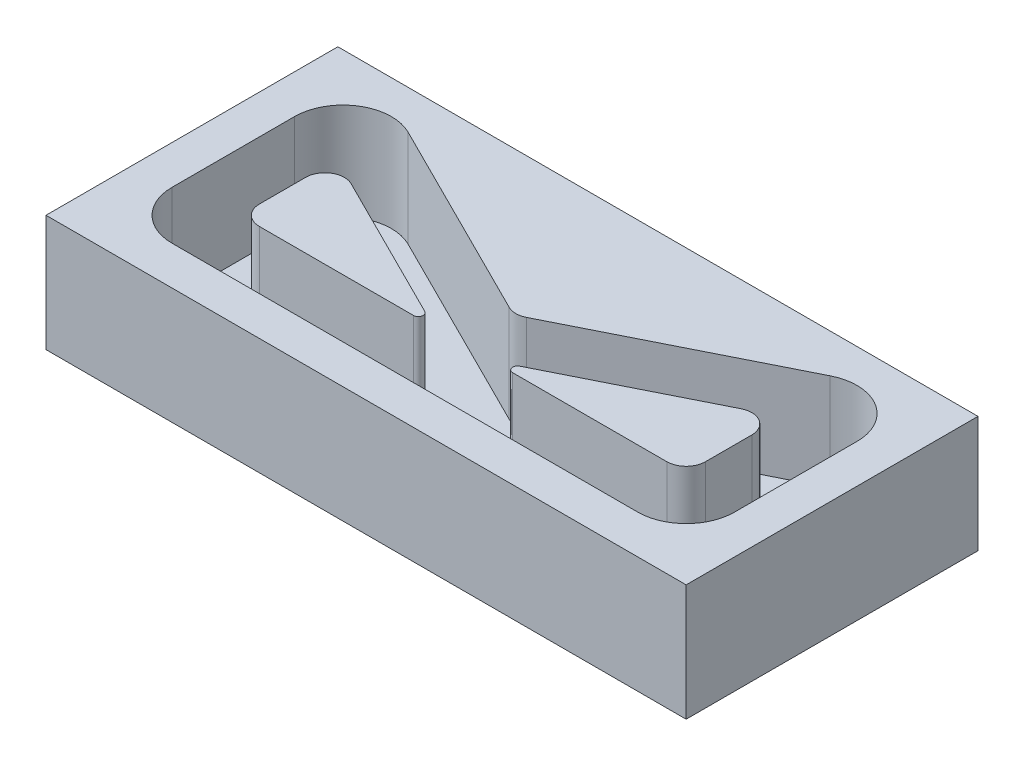
from build123d import *

# Parameters (mm, degrees)
BOSS_EXTRUDE1_DEPTH   = 5
BOSS_EXTRUDE1_2_DEPTH = 5
SKETCH1_W             = 33
SKETCH1_H             = 15.045084972
BOSS_EXTRUDE1_3_DEPTH = 5
SKETCH2_W             = 33
SKETCH2_H             = 15.045084972
BOSS_EXTRUDE3_DEPTH   = 1


with BuildPart() as part:
    # Sketch1 → Boss-Extrude1 (new body)
    with BuildSketch(Plane(origin=(0, 0, 0), x_dir=(1, 0, 0), z_dir=(0, 1, 0))):
        with BuildLine():
            Line((-0.947213595, 0.473606798), (-8.552786405, 4.276393202))
            ThreePointArc((-8.552786405, 4.276393202), (-9.525731112, 4.23261682), (-10, 3.381966011))
            Line((-10, 3.381966011), (-10, 1))
            ThreePointArc((-10, 1), (-9.707106781, 0.292893219), (-9, 0))
            Line((-9, 0), (-1.059016994, 0))
            ThreePointArc((-1.059016994, 0), (-0.815704747, 0.19256177), (-0.947213595, 0.473606798))
        make_face()
    extrude(amount=BOSS_EXTRUDE1_DEPTH)



with BuildPart() as body_2:
    # Sketch1 → Boss-Extrude1 2 (new body)
    with BuildSketch(Plane(origin=(0, 0, 0), x_dir=(1, 0, 0), z_dir=(0, 1, 0))):
        with BuildLine():
            Line((12, 0), (4.059016994, 0))
            ThreePointArc((4.059016994, 0), (3.815704747, 0.19256177), (3.947213595, 0.473606798))
            Line((3.947213595, 0.473606798), (11.552786405, 4.276393202))
            ThreePointArc((11.552786405, 4.276393202), (12.525731112, 4.23261682), (13, 3.381966011))
            Line((13, 3.381966011), (13, 1))
            ThreePointArc((13, 1), (12.707106781, 0.292893219), (12, 0))
        make_face()
    extrude(amount=BOSS_EXTRUDE1_2_DEPTH)


with BuildPart() as body_3:
    # Sketch1 → Boss-Extrude1 3 (new body)
    with BuildSketch(Plane(origin=(0, 0, 0), x_dir=(1, 0, 0), z_dir=(0, 1, 0))):
        with Locations((1.5, 2.522542486)):
            Rectangle(SKETCH1_W, SKETCH1_H)
        with BuildLine():
            Line((1.052786405, 2.827708764), (-9.381966011, 8.045084972))
            ThreePointArc((-9.381966011, 8.045084972), (-11.81432778, 7.935644015), (-13, 5.809016994))
            Line((-13, 5.809016994), (-13, -0.5))
            ThreePointArc((-13, -0.5), (-12.267766953, -2.267766953), (-10.5, -3))
            Line((-10.5, -3), (13.5, -3))
            ThreePointArc((13.5, -3), (15.267766953, -2.267766953), (16, -0.5))
            Line((16, -0.5), (16, 5.809016994))
            ThreePointArc((16, 5.809016994), (14.81432778, 7.935644015), (12.381966011, 8.045084972))
            Line((12.381966011, 8.045084972), (1.947213595, 2.827708764))
            ThreePointArc((1.947213595, 2.827708764), (1.5, 2.722135955), (1.052786405, 2.827708764))
        make_face(mode=Mode.SUBTRACT)
    extrude(amount=BOSS_EXTRUDE1_3_DEPTH)


with BuildPart() as part_1:
    add(part.part)

    add(body_2.part)  # Boss-Extrude3 merges body 2

    add(body_3.part)  # Boss-Extrude3 merges body 3
    # Sketch2 → Boss-Extrude3 (add)
    with BuildSketch(Plane.XZ):
        with Locations((1.5, -2.522542486)):
            Rectangle(SKETCH2_W, SKETCH2_H)
    extrude(amount=BOSS_EXTRUDE3_DEPTH)


solid = part_1.part
